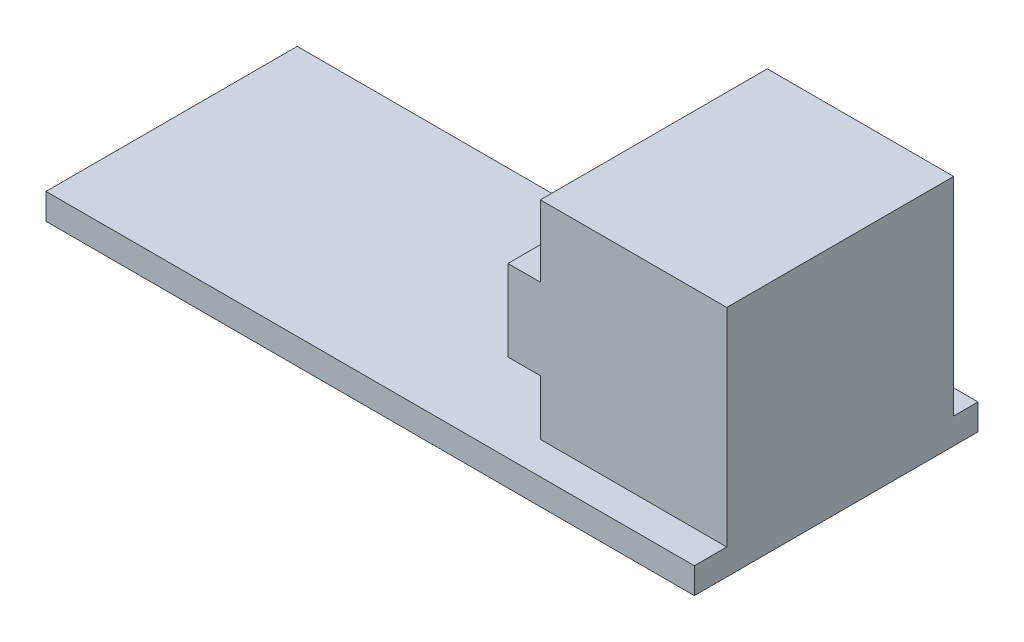
from build123d import *

# Parameters (mm, degrees)
BOSS_EXTRUDE1_DEPTH = 1.6
BOSS_EXTRUDE2_DEPTH = 14


with BuildPart() as part:
    # Sketch1 → Boss-Extrude1 (new body)
    with BuildSketch(Plane(origin=(0, 0, 0), x_dir=(1, 0, 0), z_dir=(0, 1, 0))):
        Polygon((0, 0), (0, 15.5), (26, 15.5), (26, 17.5), (40, 17.5), (40, 0), align=None)
    extrude(amount=BOSS_EXTRUDE1_DEPTH)

    # Sketch2 → Boss-Extrude2 (add)
    with BuildSketch(Plane(origin=(0, 0, -16), x_dir=(-1, 0, 0), z_dir=(0, 0, -1))):
        Polygon((-40, 1.6), (-28.5, 1.6), (-28.5, 5), (-26.5, 5), (-26.5, 10), (-28.5, 10), (-28.5, 14.4), (-40, 14.4), align=None)
    extrude(amount=-BOSS_EXTRUDE2_DEPTH)


solid = part.part
